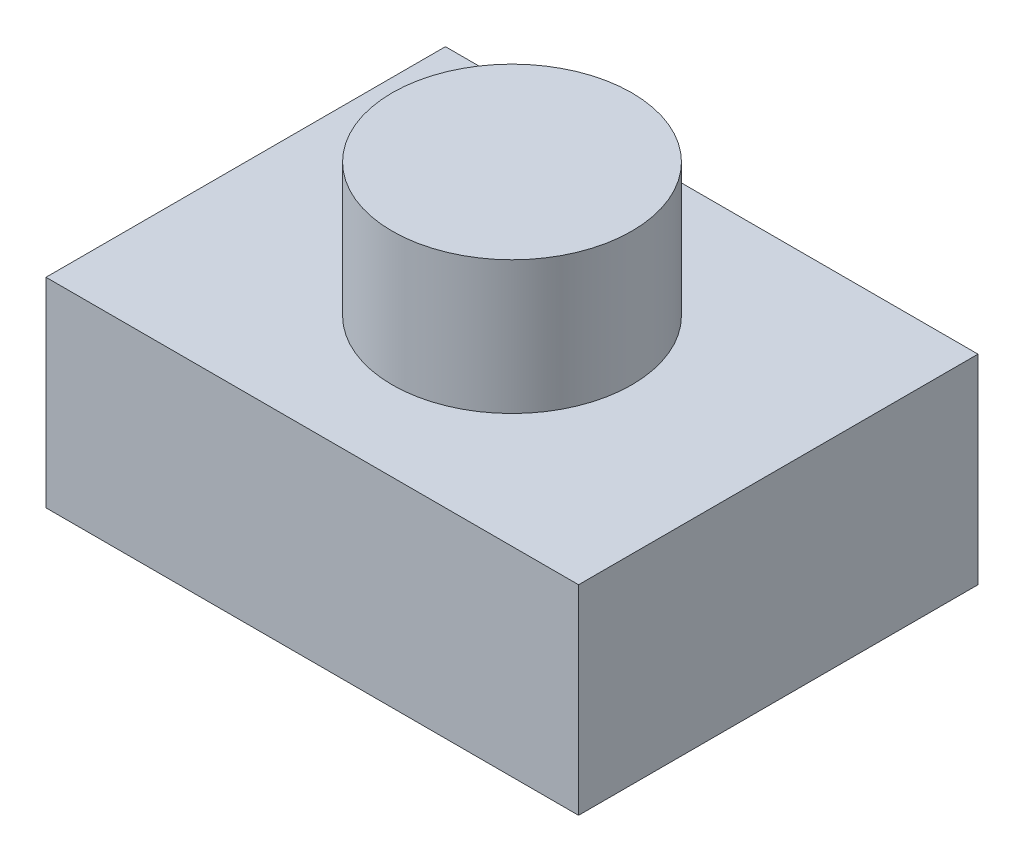
from build123d import *

# Parameters (mm, degrees)
SKETCH1_W           = 4
SKETCH1_H           = 3
BOSS_EXTRUDE1_DEPTH = 1.5
SKETCH2_R           = 0.9
BOSS_EXTRUDE2_DEPTH = 1


with BuildPart() as part:
    # Sketch1 → Boss-Extrude1 (new body)
    with BuildSketch(Plane(origin=(0, 0, 0), x_dir=(1, 0, 0), z_dir=(0, 1, 0))):
        Rectangle(SKETCH1_W, SKETCH1_H)
    extrude(amount=BOSS_EXTRUDE1_DEPTH)

    # Sketch2 → Boss-Extrude2 (add)
    with BuildSketch(Plane(origin=(0, 1.5, 0), x_dir=(1, 0, 0), z_dir=(0, 1, 0))):
        Circle(SKETCH2_R)
    extrude(amount=BOSS_EXTRUDE2_DEPTH)


solid = part.part
